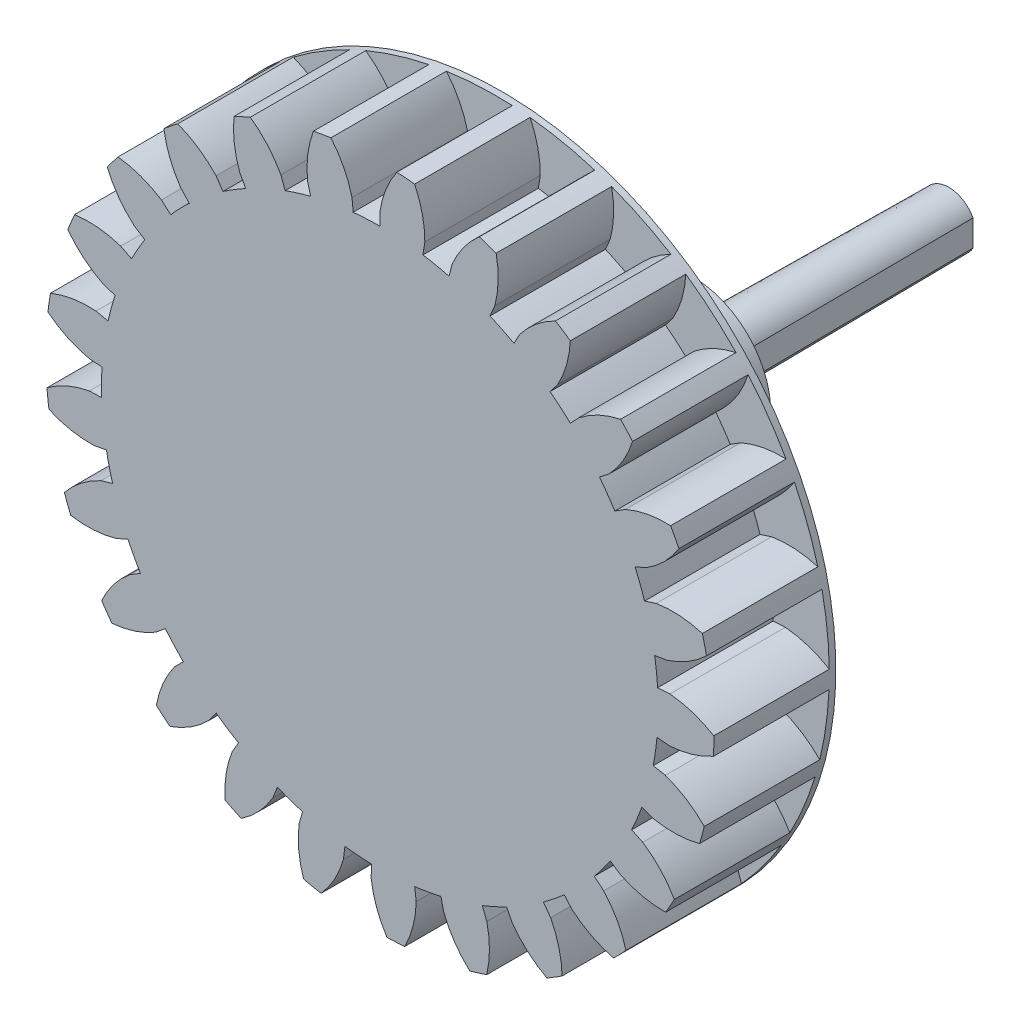
from build123d import *

# Parameters (mm, degrees)
SKETCH2_R                   = 20.25
GEAR_OUTSIDE_DIAMETER_DEPTH = 7
GEAR_TOOTH_CUT_DEPTH        = 8
GEAR_TEETH_COUNT            = 25
SKETCH3_R                   = 16.875
GEAR_DEDENDUM_CIRCLE_DEPTH  = 7
SKETCH8_R                   = 4.7
BOSS_EXTRUDE3_DEPTH         = 12
BOSS_EXTRUDE2_DEPTH         = 15.5
BOSS_EXTRUDE2_TAPER         = 0.5
SKETCH9_R                   = 20.25
BOSS_EXTRUDE4_DEPTH         = 0.4


with BuildPart() as part:
    # Sketch2 → gear outside diameter (new body)
    with BuildSketch(Plane.XY):
        Circle(SKETCH2_R)
    extrude(amount=GEAR_OUTSIDE_DIAMETER_DEPTH)

    # Sketch1 → gear tooth cut (cut, through all)
    with BuildSketch(Plane.XY):
        with BuildLine():
            Line((0, 17.61923664), (0, 16.875))
            ThreePointArc((0, 16.875), (-0.808466446, 16.855622415), (-1.615076166, 16.797534164))
            Line((-1.615076166, 16.797534164), (-1.686305728, 17.538354334))
            ThreePointArc((-1.686305728, 17.538354334), (-2.181551866, 18.85887247), (-2.96466259, 20.031806602))
            ThreePointArc((-2.96466259, 20.031806602), (-0.970159736, 20.226746898), (1.033844606, 20.223591801))
            ThreePointArc((1.033844606, 20.223591801), (0.36658824, 18.981091972), (0, 17.61923664))
        make_face()
    gear_tooth_cut = extrude(amount=GEAR_TOOTH_CUT_DEPTH, mode=Mode.SUBTRACT)

    # gear teeth: gear tooth cut ×25 about axis
    gear_teeth_axis = Axis((0, 0, 0), (0, 0, 1))
    for i in range(1, GEAR_TEETH_COUNT):
        add(gear_tooth_cut.rotate(gear_teeth_axis, i * 360 / GEAR_TEETH_COUNT), mode=Mode.SUBTRACT)

    # Sketch3 → gear dedendum circle (add)
    with BuildSketch(Plane.XY):
        Circle(SKETCH3_R)
    extrude(amount=GEAR_DEDENDUM_CIRCLE_DEPTH)

    # Sketch8 → Boss-Extrude3 (add)
    with BuildSketch(Plane(origin=(0, 0, 0), x_dir=(-1, 0, 0), z_dir=(0, 0, -1))):
        Circle(SKETCH8_R)
    extrude(amount=BOSS_EXTRUDE3_DEPTH)

    # Sketch6 → Boss-Extrude2 (add)
    with BuildSketch(Plane(origin=(0, 0, -12), x_dir=(-1, 0, 0), z_dir=(0, 0, -1))):
        with BuildLine():
            ThreePointArc((1.6, 0.824621125), (0, 1.8), (-1.6, 0.824621125))
            Line((-1.6, 0.824621125), (-1.6, -0.824621125))
            ThreePointArc((-1.6, -0.824621125), (0, -1.8), (1.6, -0.824621125))
            Line((1.6, -0.824621125), (1.6, -0.6))
            Line((1.6, -0.6), (1.697056275, -0.6))
            Line((1.697056275, -0.6), (1.697056275, 0.6))
            Line((1.697056275, 0.6), (1.6, 0.6))
            Line((1.6, 0.6), (1.6, 0.824621125))
        make_face()
    extrude(amount=BOSS_EXTRUDE2_DEPTH, taper=BOSS_EXTRUDE2_TAPER)

    # Sketch9 → Boss-Extrude4 (add)
    with BuildSketch(Plane(origin=(0, 0, 0), x_dir=(-1, 0, 0), z_dir=(0, 0, -1))):
        Circle(SKETCH9_R)
    extrude(amount=BOSS_EXTRUDE4_DEPTH)


solid = part.part
